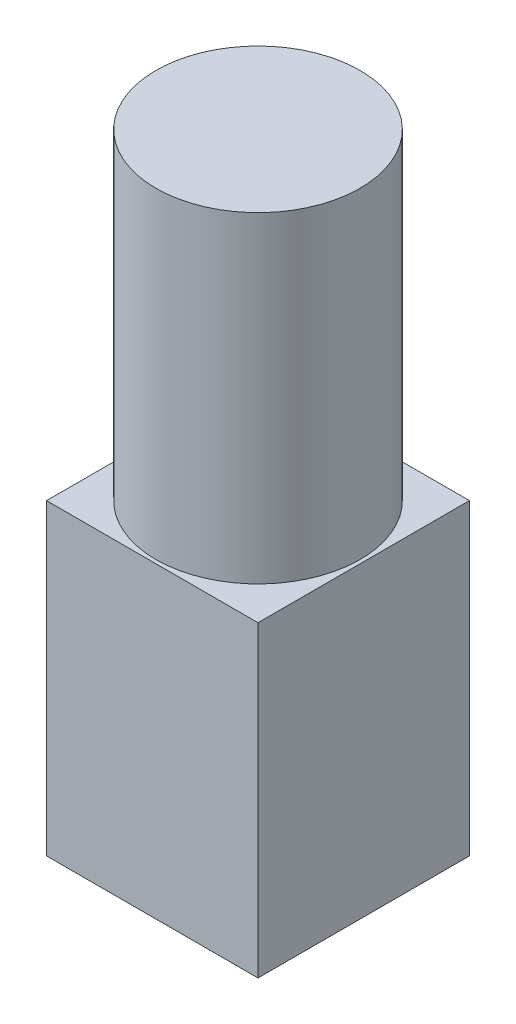
from build123d import *

# Parameters (mm, degrees)
SKETCH2_W           = 29
SKETCH2_H           = 29
BOSS_EXTRUDE4_DEPTH = 42.2
SKETCH3_R           = 14
BOSS_EXTRUDE5_DEPTH = 44.1


with BuildPart() as part:
    # Sketch2 → Boss-Extrude4 (new body)
    with BuildSketch(Plane(origin=(0, 0, 0), x_dir=(1, 0, 0), z_dir=(0, 1, 0))):
        with Locations((14.5, -14.5)):
            Rectangle(SKETCH2_W, SKETCH2_H)
    extrude(amount=BOSS_EXTRUDE4_DEPTH)

    # Sketch3 → Boss-Extrude5 (add)
    with BuildSketch(Plane(origin=(0, 42.2, 0), x_dir=(1, 0, 0), z_dir=(0, 1, 0))):
        with Locations((14.5, -14.5)):
            Circle(SKETCH3_R)
    extrude(amount=BOSS_EXTRUDE5_DEPTH)


solid = part.part
